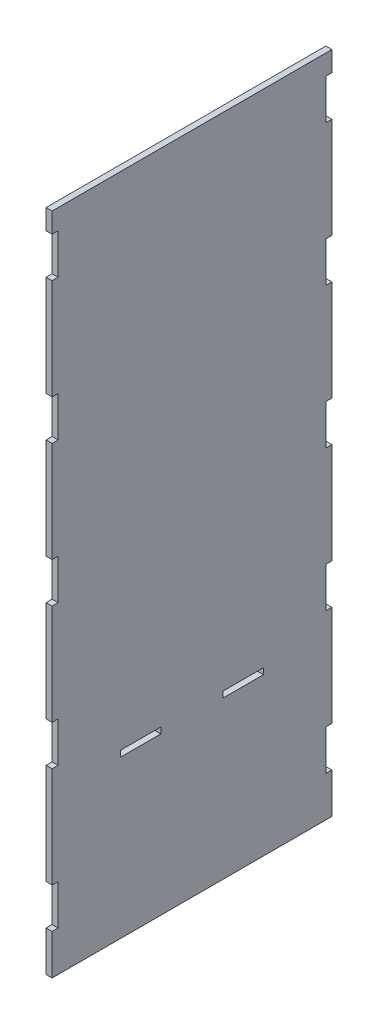
from build123d import *

# Parameters (mm, degrees)
SKETCH_1_W      = 20
SKETCH_1_H      = 3
EXTRUDE_5_DEPTH = 3


with BuildPart() as part:
    # Эскиз1 → Бобышка-Вытянуть5 (new body)
    with BuildSketch(Plane(origin=(0, 0, 0), x_dir=(0, 0, -1), z_dir=(1, 0, 0))):
        Polygon((-69.5, -165), (-69.5, -145), (-66.5, -145), (-66.5, -125), (-69.5, -125), (-69.5, -75), (-66.5, -75), (-66.5, -55), (-69.5, -55), (-69.5, -5), (-66.5, -5), (-66.5, 15), (-69.5, 15), (-69.5, 65), (-66.5, 65), (-66.5, 85), (-69.5, 85), (-69.5, 135), (-66.5, 135), (-66.5, 155), (-69.5, 155), (-69.5, 165), (69.5, 165), (69.5, 155), (66.5, 155), (66.5, 135), (69.5, 135), (69.5, 85), (66.5, 85), (66.5, 65), (69.5, 65), (69.5, 15), (66.5, 15), (66.5, -5), (69.5, -5), (69.5, -55), (66.5, -55), (66.5, -75), (69.5, -75), (69.5, -125), (66.5, -125), (66.5, -145), (69.5, -145), (69.5, -165), align=None)
        with Locations((25.5, -85.5)):
            Rectangle(SKETCH_1_W, SKETCH_1_H, mode=Mode.SUBTRACT)
        with Locations((-25.5, -85.5)):
            Rectangle(SKETCH_1_W, SKETCH_1_H, mode=Mode.SUBTRACT)
    extrude(amount=EXTRUDE_5_DEPTH)


solid = part.part
